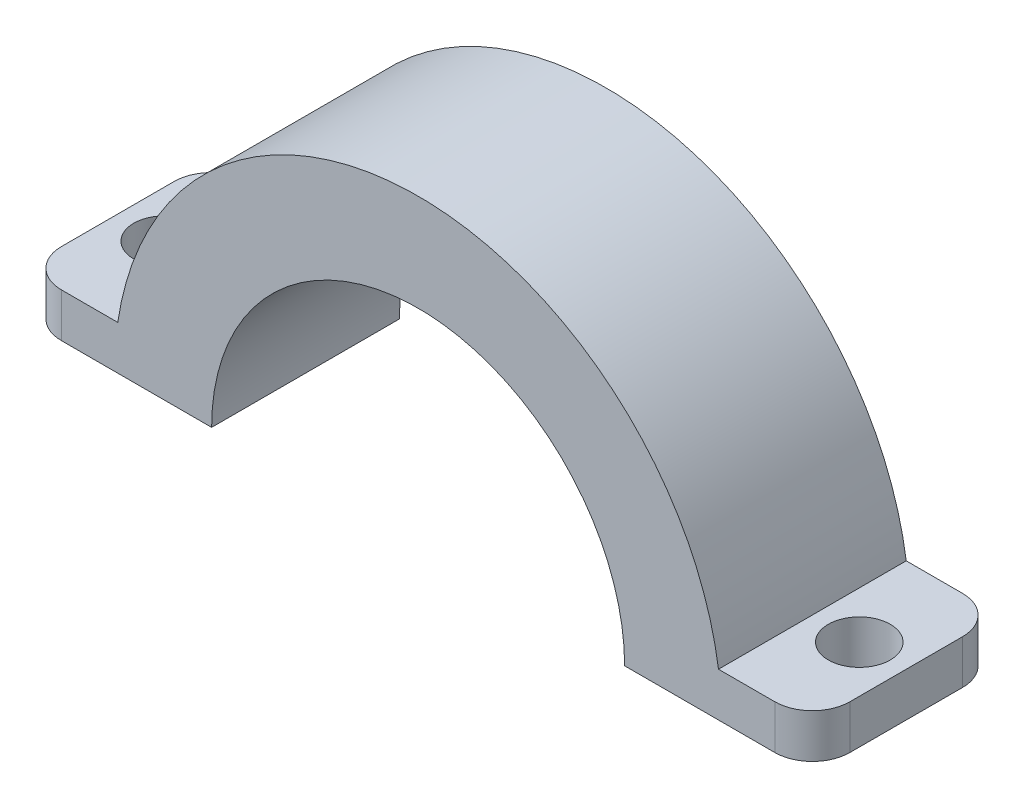
from build123d import *

# Parameters (mm, degrees)
BOSS_EXTRUDE1_DEPTH  = 10
SKETCH2_R            = 1.65
CUT_EXTRUDE1_DEPTH   = 10
FILLET1_R            = 2
FILLET1_OF_MIRROR1_R = 2


with BuildPart() as part:
    # Sketch1 → Boss-Extrude1 (new body)
    with BuildSketch(Plane.XY):
        with BuildLine():
            Line((-21, 0), (-11, 0))
            ThreePointArc((-11, 0), (-7.778174593, 7.778174593), (0, 11))
            Line((0, 11), (0, 16.170747429))
            ThreePointArc((0, 16.170747429), (-10.573391114, 12.235050991), (-16, 2.343730447))
            Line((-16, 2.343730447), (-21, 2.343730447))
            Line((-21, 2.343730447), (-21, 0))
        make_face()
    boss_extrude1 = extrude(amount=BOSS_EXTRUDE1_DEPTH)

    # Sketch2 → Cut-Extrude1 (cut)
    with BuildSketch(Plane(origin=(0, 2.343730447, 0), x_dir=(1, 0, 0), z_dir=(0, 1, 0))):
        with Locations((-18.5, -5)):
            Circle(SKETCH2_R)
    cut_extrude1 = extrude(amount=-CUT_EXTRUDE1_DEPTH, mode=Mode.SUBTRACT)

    # Fillet1
    fillet1_edges = [part.edges().sort_by_distance(p)[0] for p in [
        (-21, 1.171865223, 10),
        (-21, 1.171865223, 0),
    ]]
    fillet(fillet1_edges, radius=FILLET1_R)

    # Mirror1: Boss-Extrude1, Cut-Extrude1 across plane
    add(boss_extrude1.mirror(Plane(origin=(0, 11, 10), x_dir=(0, 0, 1), z_dir=(-1, 0, 0))))
    add(cut_extrude1.mirror(Plane(origin=(0, 11, 10), x_dir=(0, 0, 1), z_dir=(-1, 0, 0))), mode=Mode.SUBTRACT)

    # Fillet1 of Mirror1
    fillet1_of_mirror1_edges = [part.edges().sort_by_distance(p)[0] for p in [
        (21, 1.171865223, 10),
        (21, 1.171865223, 0),
    ]]
    fillet(fillet1_of_mirror1_edges, radius=FILLET1_OF_MIRROR1_R)


solid = part.part
